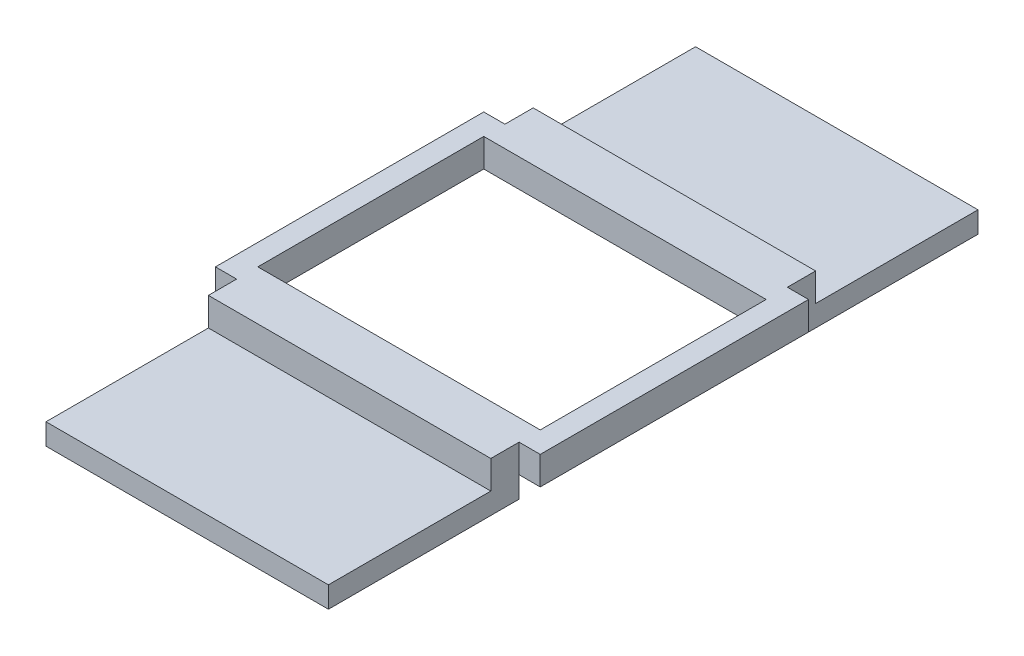
from build123d import *

# Parameters (mm, degrees)
SKETCH1_W             = 23
SKETCH1_H             = 19
SKETCH1_W_2           = 20
SKETCH1_H_2           = 16
BOSS_EXTRUDE1_DEPTH   = 2
SKETCH2_W             = 20
SKETCH2_H             = 13.5
BOSS_EXTRUDE3_DEPTH   = 1.5
BOSS_EXTRUDE3_2_DEPTH = 1.5
SKETCH3_W             = 20
SKETCH3_H             = 2
BOSS_EXTRUDE4_DEPTH   = 2


with BuildPart() as part:
    # Sketch1 → Boss-Extrude1 (new body)
    with BuildSketch(Plane(origin=(0, 0, 0), x_dir=(1, 0, 0), z_dir=(0, 1, 0))):
        Rectangle(SKETCH1_W, SKETCH1_H)
        Rectangle(SKETCH1_W_2, SKETCH1_H_2, mode=Mode.SUBTRACT)
    extrude(amount=BOSS_EXTRUDE1_DEPTH)



with BuildPart() as body_2:
    # Sketch2 → Boss-Extrude3 (new body)
    with BuildSketch(Plane.XZ):
        with Locations((0, 16.25)):
            Rectangle(SKETCH2_W, SKETCH2_H)
    extrude(amount=BOSS_EXTRUDE3_DEPTH)


with BuildPart() as body_3:
    # Sketch2 → Boss-Extrude3 2 (new body)
    with BuildSketch(Plane.XZ):
        with Locations((0, -16.25)):
            Rectangle(SKETCH2_W, SKETCH2_H)
    extrude(amount=BOSS_EXTRUDE3_2_DEPTH)


with BuildPart() as part_1:
    add(part.part)

    add(body_2.part)  # Boss-Extrude4 merges body 2

    add(body_3.part)  # Boss-Extrude4 merges body 3
    # Sketch3 → Boss-Extrude4 (add)
    with BuildSketch(Plane(origin=(0, 0, 0), x_dir=(1, 0, 0), z_dir=(0, 1, 0))):
        with Locations((0, 10.5)):
            Rectangle(SKETCH3_W, SKETCH3_H)
        with Locations((0, -10.5)):
            Rectangle(SKETCH3_W, SKETCH3_H)
    extrude(amount=BOSS_EXTRUDE4_DEPTH)


solid = part_1.part
